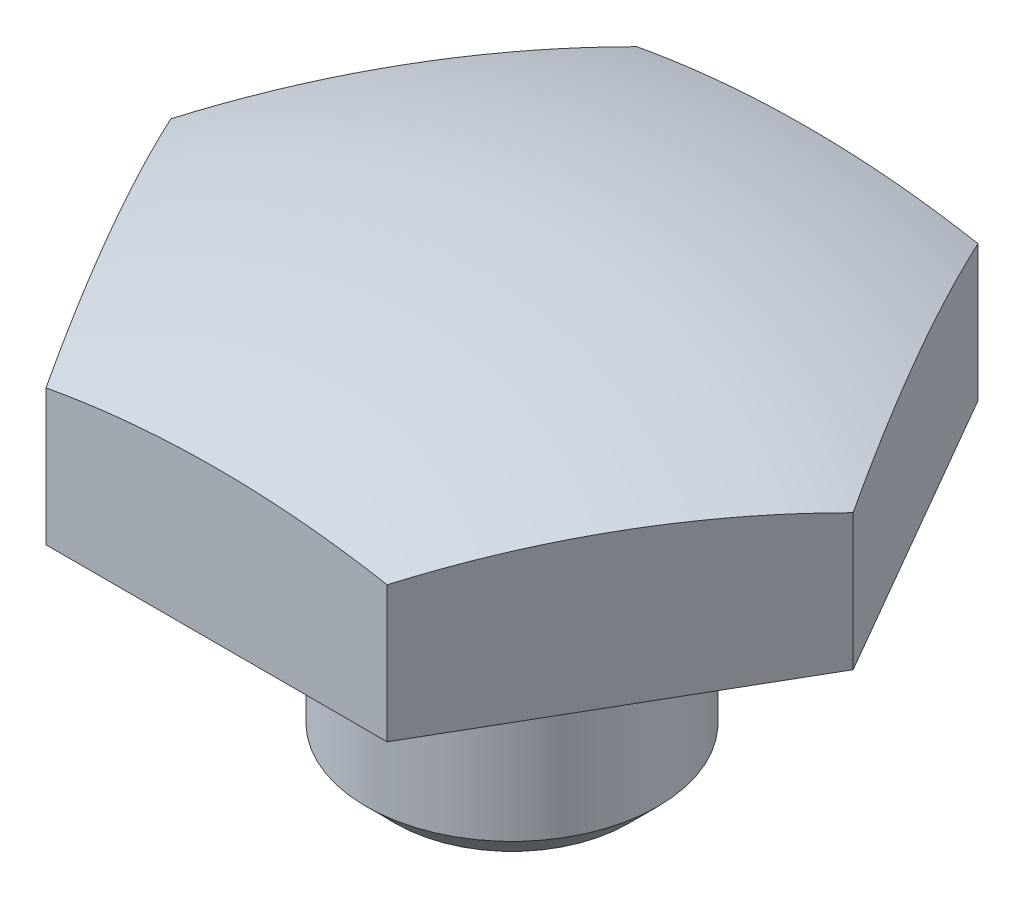
from build123d import *

# Parameters (mm, degrees)
CUT_EXTRUDE2_DEPTH = 14.2748


with BuildPart() as part:
    # Sketch3 → Revolve1 (revolve)
    with BuildSketch(Plane.XY):
        with BuildLine():
            Line((4.699, 4.9911), (4.699, 0.9525))
            Line((4.699, 0.9525), (3.7465, 0))
            Line((3.7465, 0), (0, 0))
            Line((0, 0), (0, 14.2748))
            ThreePointArc((0, 14.2748), (5.586411751, 13.779471711), (10.9985175, 12.308941969))
            Line((10.9985175, 12.308941969), (10.9985175, 7.9248))
            Line((10.9985175, 7.9248), (4.1275, 7.9248))
            ThreePointArc((4.1275, 7.9248), (3.858092316, 7.813207684), (3.7465, 7.5438))
            Line((3.7465, 7.5438), (3.7465, 5.9436))
            Line((3.7465, 5.9436), (4.699, 4.9911))
        make_face()
    revolve(axis=Axis((0, -1000, 0), (0, 1, 0)))

    # Sketch1 → Cut-Extrude2 (cut)
    with BuildSketch(Plane(origin=(0, 0, 0), x_dir=(1, 0, 0), z_dir=(0, 1, 0))):
        with BuildLine():
            ThreePointArc((-5.499261314, -9.525), (0, -10.998522628), (5.499261314, -9.525))
            Line((5.499261314, -9.525), (-5.499261314, -9.525))
        make_face()
        with BuildLine():
            ThreePointArc((-10.998522628, 0), (-9.525, -5.499261314), (-5.499261314, -9.525))
            Line((-5.499261314, -9.525), (-10.998522628, 0))
        make_face()
        with BuildLine():
            ThreePointArc((5.499261314, -9.525), (9.525, -5.499261314), (10.998522628, 0))
            Line((10.998522628, 0), (5.499261314, -9.525))
        make_face()
        with BuildLine():
            Line((5.499261314, 9.525), (10.998522628, 0))
            ThreePointArc((10.998522628, 0), (9.525, 5.499261314), (5.499261314, 9.525))
        make_face()
        with BuildLine():
            Line((-5.499261314, 9.525), (5.499261314, 9.525))
            ThreePointArc((5.499261314, 9.525), (0, 10.998522628), (-5.499261314, 9.525))
        make_face()
        with BuildLine():
            Line((-10.998522628, 0), (-5.499261314, 9.525))
            ThreePointArc((-5.499261314, 9.525), (-9.525, 5.499261314), (-10.998522628, 0))
        make_face()
    extrude(amount=CUT_EXTRUDE2_DEPTH, mode=Mode.SUBTRACT)


solid = part.part
